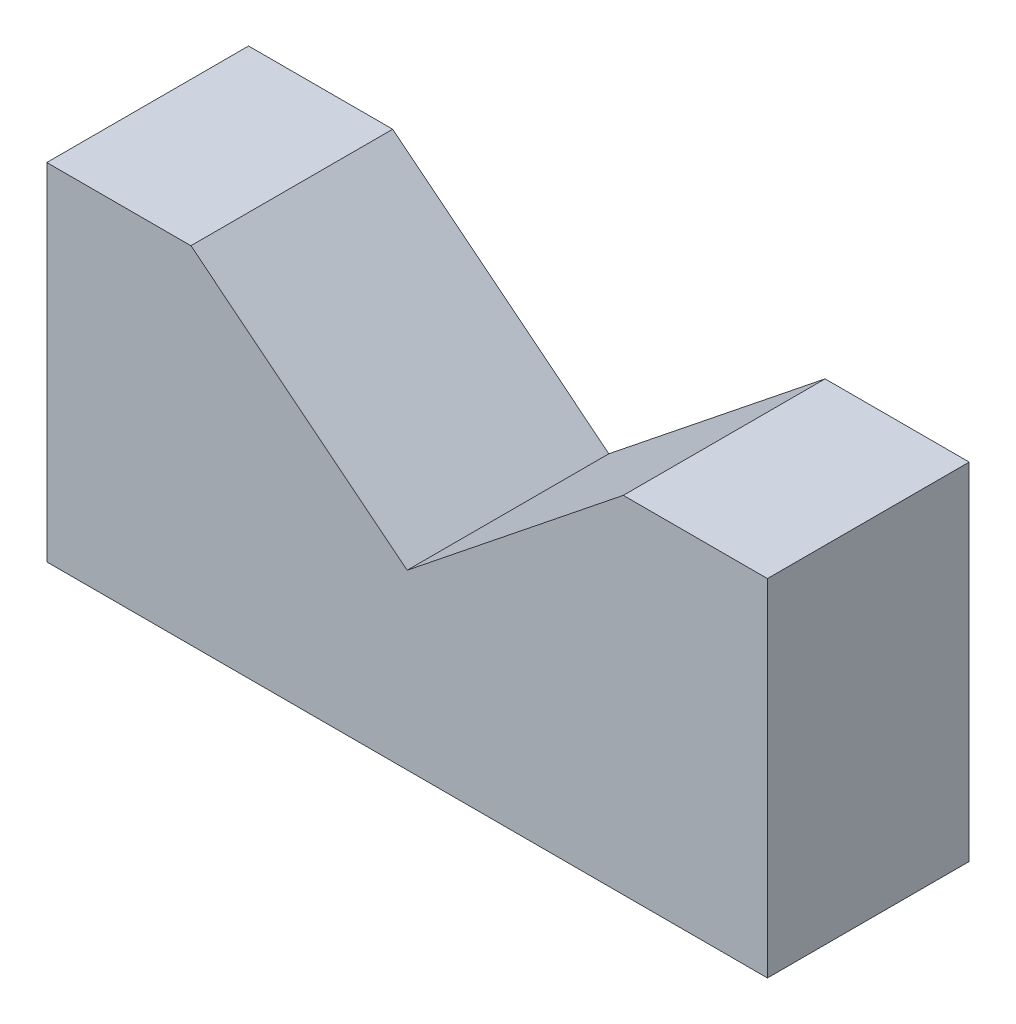
from build123d import *

# Parameters (mm, degrees)
Y_KSEKLIK_EKSTR_ZYON1_DEPTH = 70


with BuildPart() as part:
    # Çizim1 → Yükseklik-Ekstrüzyon1 (new body)
    with BuildSketch(Plane.XY):
        Polygon((-125, 0), (125, 0), (125, 120), (75, 120), (0, 60), (-75, 120), (-125, 120), align=None)
    extrude(amount=Y_KSEKLIK_EKSTR_ZYON1_DEPTH)


solid = part.part
